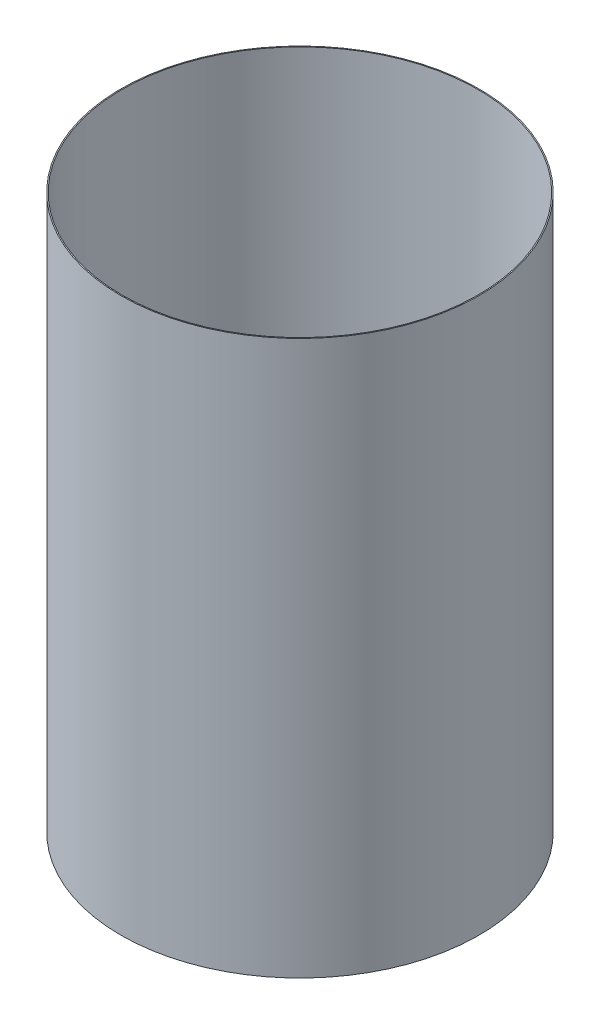
from build123d import *

# Parameters (mm, degrees)
SKETCH1_W = 0.254
SKETCH1_H = 133.35


with BuildPart() as part:
    # Sketch1 → Revolve-Thin1 (revolve)
    with BuildSketch(Plane.XY):
        with Locations((-42.9895, -135.67819341)):
            Rectangle(SKETCH1_W, SKETCH1_H)
    revolve(axis=Axis((0, 55, 0), (0, -1, 0)))


solid = part.part
